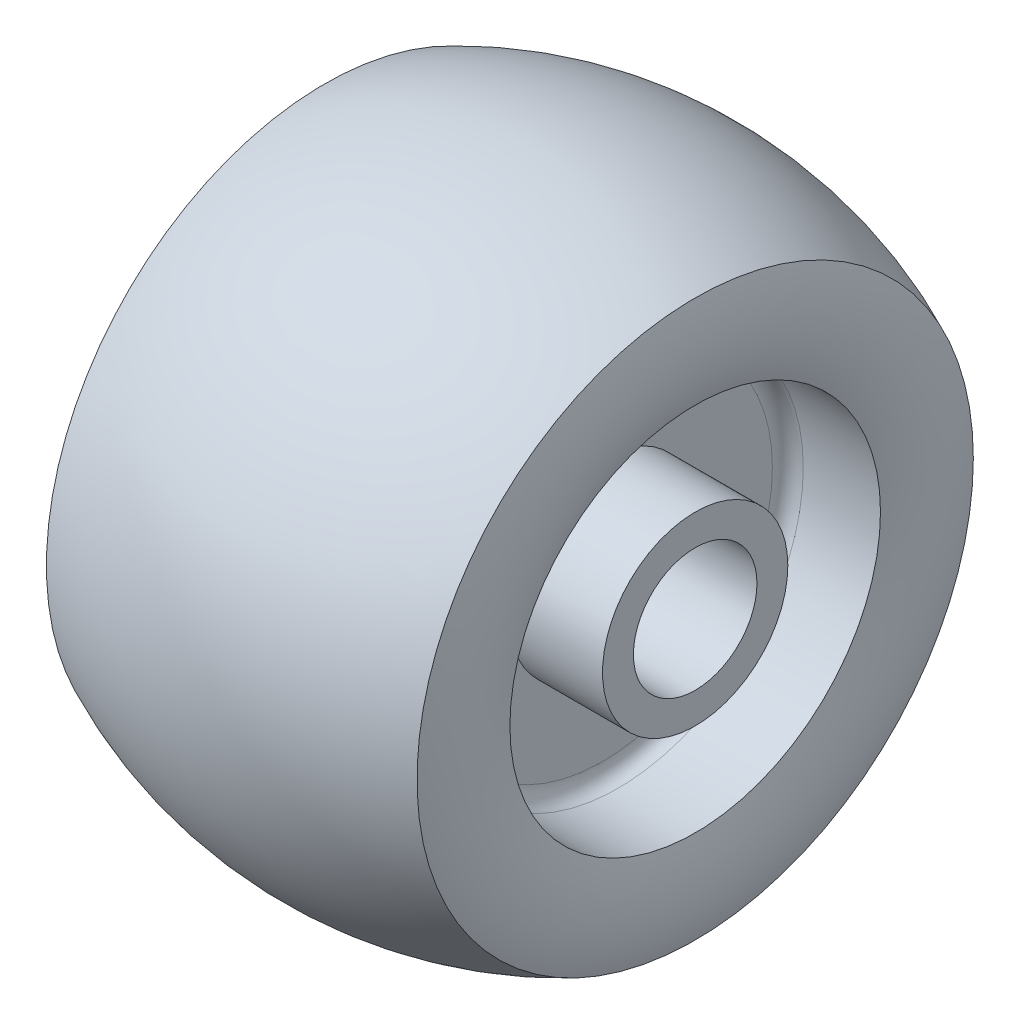
from build123d import *

# Parameters (mm, degrees)
BOSS_EXTRUDE1_START = -112.436685
SKETCH2_R           = 30
BOSS_EXTRUDE1_DEPTH = 112.436685
SKETCH3_R           = 30
BOSS_EXTRUDE2_DEPTH = 10
SKETCH4_R           = 20
CUT_EXTRUDE1_DEPTH  = 125.873370497


with BuildPart() as part:
    # Sketch1 → Revolve1 (revolve)
    with BuildSketch(Plane.XY):
        with BuildLine():
            Line((0, 0), (-50, 0))
            Line((-50, 0), (-50, 10))
            Line((-50, 10), (-30, 10))
            Line((-30, 10), (-30, 55))
            ThreePointArc((-30, 55), (-31.464466094, 58.535533906), (-35, 60))
            Line((-35, 60), (-60, 60))
            ThreePointArc((-60, 60), (-62.436685199, 75.031545588), (-60, 90.063091176))
            ThreePointArc((-60, 90.063091176), (0, 103.36161645), (60, 90.063091176))
            ThreePointArc((60, 90.063091176), (62.436685199, 75.031545588), (60, 60))
            Line((60, 60), (35, 60))
            ThreePointArc((35, 60), (31.464466094, 58.535533906), (30, 55))
            Line((30, 55), (30, 10))
            Line((30, 10), (50, 10))
            Line((50, 10), (50, 0))
            Line((50, 0), (0, 0))
        make_face()
    revolve(axis=Axis((0, 0, 0), (-1, 0, 0)))

    # Sketch2 → Boss-Extrude1 (add)
    with BuildSketch(Plane(origin=(50, 0, 0), x_dir=(0, 0, -1), z_dir=(1, 0, 0)).offset(BOSS_EXTRUDE1_START)):
        Circle(SKETCH2_R)
    extrude(amount=BOSS_EXTRUDE1_DEPTH)

    # Sketch3 → Boss-Extrude2 (add)
    with BuildSketch(Plane(origin=(50, 0, 0), x_dir=(0, 0, -1), z_dir=(1, 0, 0))):
        Circle(SKETCH3_R)
    extrude(amount=BOSS_EXTRUDE2_DEPTH)

    # Sketch4 → Cut-Extrude1 (cut, through all)
    with BuildSketch(Plane.ZY.offset(62.436685199)):
        Circle(SKETCH4_R)
    extrude(amount=-CUT_EXTRUDE1_DEPTH, mode=Mode.SUBTRACT)


solid = part.part
